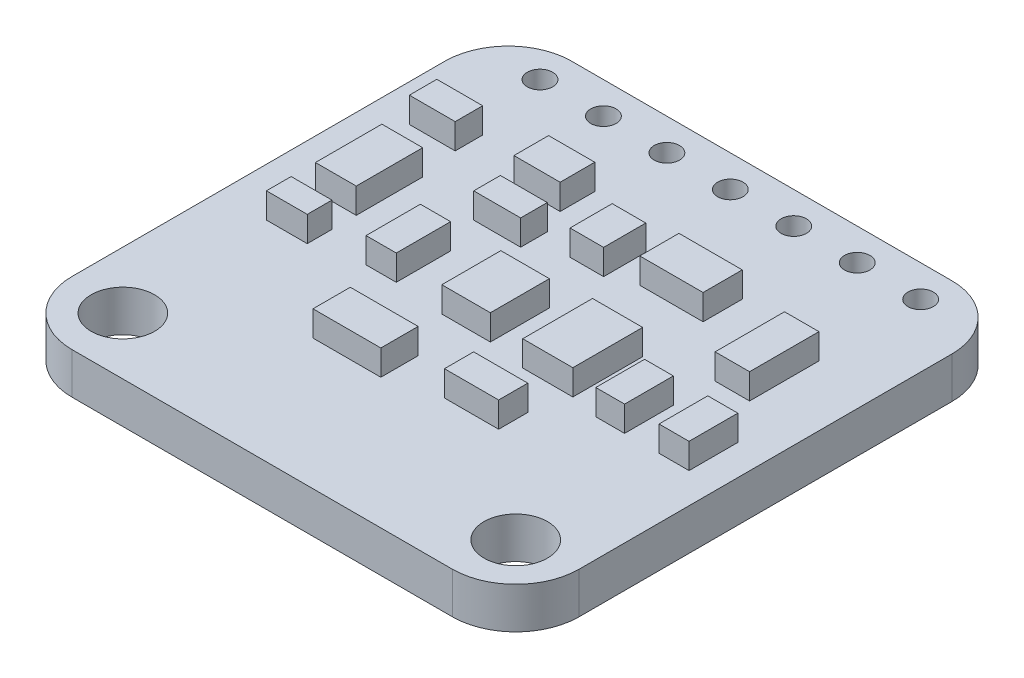
from build123d import *

# Parameters (mm, degrees)
PCB_DEPTH          = 1.651
SKETCH2_R          = 1.27
SKETCH2_R_2        = 0.508
CUT_EXTRUDE1_DEPTH = 2.651
SKETCH3_W          = 1.9431
SKETCH3_H          = 2.3622
SKETCH3_W_2        = 2.0066
SKETCH3_H_2        = 2.794
SKETCH3_W_3        = 2.16822249
SKETCH3_H_3        = 1.167787324
SKETCH3_W_4        = 2.716171955
SKETCH3_H_4        = 1.493517176
SKETCH3_W_5        = 1.209663862
SKETCH3_H_5        = 2.17508788
SKETCH3_W_6        = 1.633321627
SKETCH3_H_6        = 2.659890245
SKETCH3_W_7        = 1.834361491
SKETCH3_H_7        = 1.100221283
SKETCH3_W_8        = 1.848311781
SKETCH3_H_8        = 1.38602823
SKETCH3_W_9        = 1.877433771
SKETCH3_H_9        = 1.066217503
SKETCH3_H_10       = 0.988618516
SKETCH3_W_10       = 1.152895283
SKETCH3_H_11       = 1.952725423
SKETCH3_W_11       = 1.201658639
SKETCH3_W_12       = 1.378437796
SKETCH3_H_12       = 2.778082819
SKETCH3_W_13       = 2.534678464
SKETCH3_H_13       = 1.568516227
SKETCH3_W_14       = 1.344087022
SKETCH3_H_14       = 1.688234225
COMPONENTS_DEPTH   = 1.016


with BuildPart() as part:
    # Sketch1 → pcb (new body)
    with BuildSketch(Plane(origin=(0, 0, 0), x_dir=(1, 0, 0), z_dir=(0, 1, 0))):
        with BuildLine():
            Line((-7.61, -10), (7.61, -10))
            ThreePointArc((7.61, -10), (9.406051224, -9.256051224), (10.15, -7.46))
            Line((10.15, -7.46), (10.15, 7.46))
            ThreePointArc((10.15, 7.46), (9.406051224, 9.256051224), (7.61, 10))
            Line((7.61, 10), (-7.61, 10))
            ThreePointArc((-7.61, 10), (-9.406051224, 9.256051224), (-10.15, 7.46))
            Line((-10.15, 7.46), (-10.15, -7.46))
            ThreePointArc((-10.15, -7.46), (-9.406051224, -9.256051224), (-7.61, -10))
        make_face()
    extrude(amount=PCB_DEPTH)

    # Sketch2 → Cut-Extrude1 (cut, through all)
    with BuildSketch(Plane.XZ):
        with Locations((-7.864, 7.714)):
            Circle(SKETCH2_R)
        with Locations((7.864, 7.714)):
            Circle(SKETCH2_R)
        with Locations((-7.61, -8.73)):
            Circle(SKETCH2_R_2)
        with Locations((-5.07, -8.73)):
            Circle(SKETCH2_R_2)
        with Locations((-2.53, -8.73)):
            Circle(SKETCH2_R_2)
        with Locations((0.01, -8.73)):
            Circle(SKETCH2_R_2)
        with Locations((2.55, -8.73)):
            Circle(SKETCH2_R_2)
        with Locations((5.09, -8.73)):
            Circle(SKETCH2_R_2)
        with Locations((7.63, -8.73)):
            Circle(SKETCH2_R_2)
    extrude(amount=-CUT_EXTRUDE1_DEPTH, mode=Mode.SUBTRACT)

    # Sketch3 → components (add)
    with BuildSketch(Plane(origin=(0, 1.651, 0), x_dir=(1, 0, 0), z_dir=(0, 1, 0))):
        with Locations((-0.47355, -0.1829)):
            Rectangle(SKETCH3_W, SKETCH3_H)
        with Locations((3.0507, -0.221)):
            Rectangle(SKETCH3_W_2, SKETCH3_H_2)
        with Locations((2.603432781, -3.639116092)):
            Rectangle(SKETCH3_W_3, SKETCH3_H_3)
        with Locations((-1.831635977, -4.030732119)):
            Rectangle(SKETCH3_W_4, SKETCH3_H_4)
        with Locations((-4.061190046, -0.08934394)):
            Rectangle(SKETCH3_W_5, SKETCH3_H_5)
        with Locations((-7.395465276, 1.673424229)):
            Rectangle(SKETCH3_W_6, SKETCH3_H_6)
        with Locations((-7.750024191, 5.108202568)):
            Rectangle(SKETCH3_W_7, SKETCH3_H_7)
        with Locations((-3.555135742, 5.251106041)):
            Rectangle(SKETCH3_W_8, SKETCH3_H_8)
        with Locations((-3.122473161, 3.062543074)):
            Rectangle(SKETCH3_W_9, SKETCH3_H_9)
        with Locations((-7.395465276, -1.123690742)):
            Rectangle(SKETCH3_W_6, SKETCH3_H_10)
        with Locations((5.77539067, -0.868377737)):
            Rectangle(SKETCH3_W_10, SKETCH3_H_11)
        with Locations((8.331105427, -0.868377737)):
            Rectangle(SKETCH3_W_11, SKETCH3_H_11)
        with Locations((7.041057209, 3.169050517)):
            Rectangle(SKETCH3_W_12, SKETCH3_H_12)
        with Locations((2.786660768, 4.379909938)):
            Rectangle(SKETCH3_W_13, SKETCH3_H_13)
        with Locations((-0.174043511, 4.013167629)):
            Rectangle(SKETCH3_W_14, SKETCH3_H_14)
    extrude(amount=COMPONENTS_DEPTH)


solid = part.part
